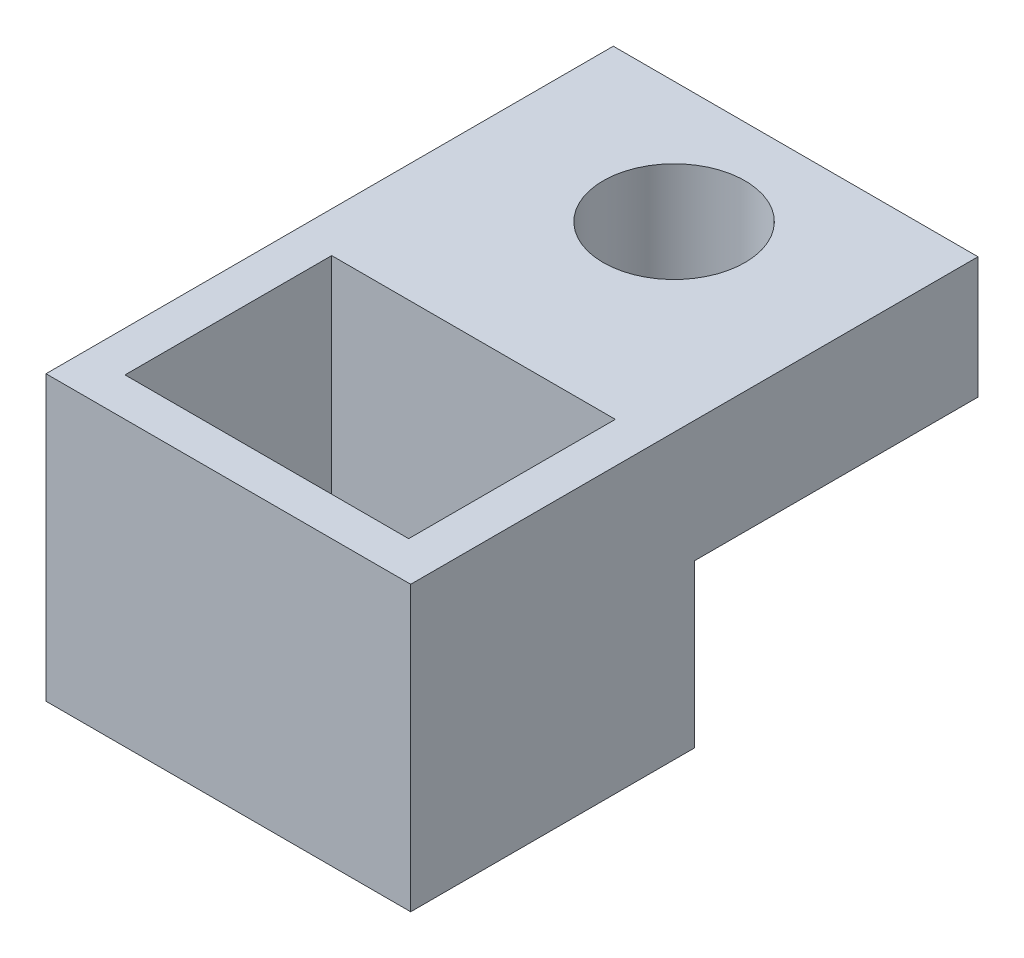
from build123d import *

# Parameters (mm, degrees)
BOSS_EXTRUDE2_DEPTH = 9
SKETCH6_R           = 1.75
SKETCH6_W           = 7
SKETCH6_H           = 5.1
CUT_EXTRUDE1_DEPTH  = 8


with BuildPart() as part:
    # Sketch4 → Boss-Extrude2 (new body)
    with BuildSketch(Plane(origin=(0, 0, 0), x_dir=(0, 0, -1), z_dir=(1, 0, 0))):
        Polygon((0, 0), (0, -4), (-7, -4), (-7, 3), (7, 3), (7, 0), align=None)
    extrude(amount=BOSS_EXTRUDE2_DEPTH)

    # Sketch6 → Cut-Extrude1 (cut, through all)
    with BuildSketch(Plane(origin=(0, 3, 0), x_dir=(1, 0, 0), z_dir=(0, 1, 0))):
        with Locations((4.5, 4)):
            Circle(SKETCH6_R)
        with Locations((4.5, -3.5)):
            Rectangle(SKETCH6_W, SKETCH6_H)
    extrude(amount=-CUT_EXTRUDE1_DEPTH, mode=Mode.SUBTRACT)


solid = part.part
